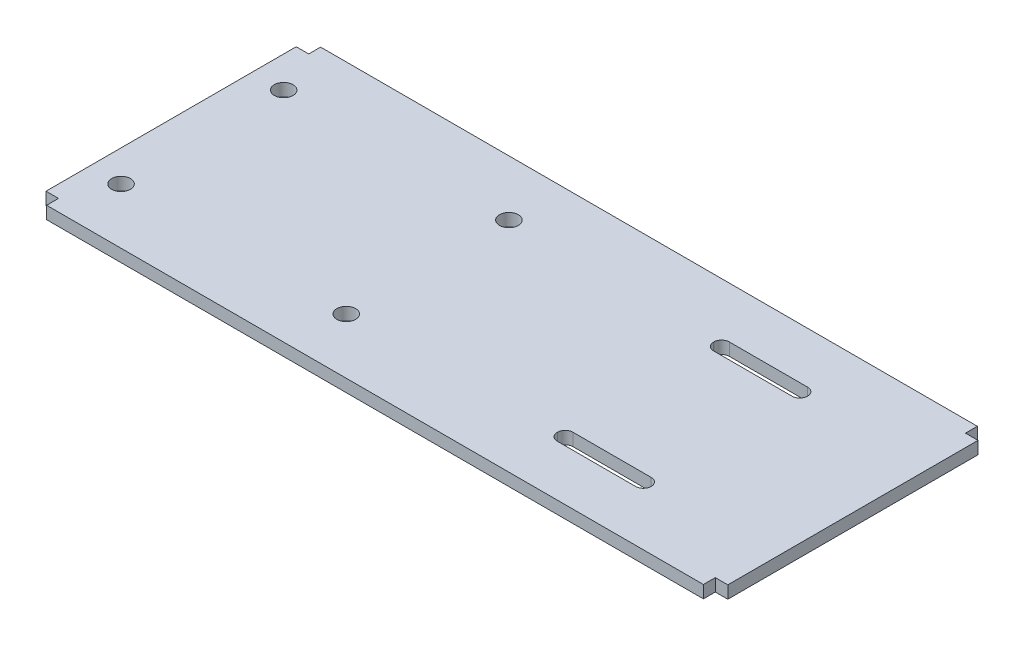
from build123d import *

# Parameters (mm, degrees)
BOSS_EXTRUDE1_DEPTH = 2.54
CUT_EXTRUDE1_DEPTH  = 3.54
CUT_EXTRUDE2_DEPTH  = 3.54


with BuildPart() as part:
    # Sketch1 → Boss-Extrude1 (new body)
    with BuildSketch(Plane(origin=(0, 0, 0), x_dir=(1, 0, 0), z_dir=(0, 1, 0))):
        Polygon((-66.675, 25.4), (-69.215, 25.4), (-69.215, -25.4), (-66.675, -25.4), (-66.675, -27.813), (66.675, -27.813), (66.675, -25.4), (69.215, -25.4), (69.215, 25.4), (66.675, 25.4), (66.675, 27.813), (-66.675, 27.813), align=None)
    extrude(amount=BOSS_EXTRUDE1_DEPTH)

    # Sketch2 → Cut-Extrude1 (cut, through all)
    with BuildSketch(Plane(origin=(0, 2.54, 0), x_dir=(1, 0, 0), z_dir=(0, 1, 0))):
        with BuildLine():
            ThreePointArc((-60.96, 16.51), (-64.212038418, 17.857038418), (-62.865, 14.605))
            Line((-62.865, 14.605), (-62.865, 16.51))
            Line((-62.865, 16.51), (-60.96, 16.51))
        make_face()
        with BuildLine():
            Line((-62.865, 16.51), (-62.865, 14.605))
            ThreePointArc((-62.865, 14.605), (-61.517961582, 15.162961582), (-60.96, 16.51))
            Line((-60.96, 16.51), (-62.865, 16.51))
        make_face()
        with BuildLine():
            ThreePointArc((-19.05, 16.51), (-18.492038418, 15.162961582), (-17.145, 14.605))
            Line((-17.145, 14.605), (-17.145, 16.51))
            Line((-17.145, 16.51), (-19.05, 16.51))
        make_face()
        with BuildLine():
            Line((-17.145, 16.51), (-17.145, 14.605))
            ThreePointArc((-17.145, 14.605), (-15.797961582, 15.162961582), (-15.24, 16.51))
            ThreePointArc((-15.24, 16.51), (-17.145, 18.415), (-19.05, 16.51))
            Line((-19.05, 16.51), (-17.145, 16.51))
        make_face()
        with BuildLine():
            ThreePointArc((-17.145, -14.605), (-18.492038418, -15.162961582), (-19.05, -16.51))
            Line((-19.05, -16.51), (-17.145, -16.51))
            Line((-17.145, -16.51), (-17.145, -14.605))
        make_face()
        with BuildLine():
            Line((-17.145, -16.51), (-19.05, -16.51))
            ThreePointArc((-19.05, -16.51), (-17.145, -18.415), (-15.24, -16.51))
            ThreePointArc((-15.24, -16.51), (-15.797961582, -15.162961582), (-17.145, -14.605))
            Line((-17.145, -14.605), (-17.145, -16.51))
        make_face()
        with BuildLine():
            Line((-62.865, -14.605), (-62.865, -16.51))
            Line((-62.865, -16.51), (-60.96, -16.51))
            ThreePointArc((-60.96, -16.51), (-61.517961582, -15.162961582), (-62.865, -14.605))
        make_face()
        with BuildLine():
            Line((-60.96, -16.51), (-62.865, -16.51))
            Line((-62.865, -16.51), (-62.865, -14.605))
            ThreePointArc((-62.865, -14.605), (-64.212038418, -17.857038418), (-60.96, -16.51))
        make_face()
    extrude(amount=-CUT_EXTRUDE1_DEPTH, mode=Mode.SUBTRACT)

    # Sketch3 → Cut-Extrude2 (cut, through all)
    with BuildSketch(Plane(origin=(0, 2.54, 0), x_dir=(1, 0, 0), z_dir=(0, 1, 0))):
        with BuildLine():
            Line((44.1325, 15.8877), (44.1325, 15.8623))
            ThreePointArc((44.1325, 15.8623), (43.671251759, 14.748748241), (42.5577, 14.2875))
            Line((42.5577, 14.2875), (26.6573, 14.2875))
            ThreePointArc((26.6573, 14.2875), (25.543748241, 14.748748241), (25.0825, 15.8623))
            Line((25.0825, 15.8623), (25.0825, 15.8877))
            ThreePointArc((25.0825, 15.8877), (25.543748241, 17.001251759), (26.6573, 17.4625))
            Line((26.6573, 17.4625), (42.5577, 17.4625))
            ThreePointArc((42.5577, 17.4625), (43.671251759, 17.001251759), (44.1325, 15.8877))
        make_face()
        with BuildLine():
            Line((42.5577, -17.4625), (26.6573, -17.4625))
            ThreePointArc((26.6573, -17.4625), (25.543748241, -17.001251759), (25.0825, -15.8877))
            Line((25.0825, -15.8877), (25.0825, -15.8623))
            ThreePointArc((25.0825, -15.8623), (25.543748241, -14.748748241), (26.6573, -14.2875))
            Line((26.6573, -14.2875), (42.5577, -14.2875))
            ThreePointArc((42.5577, -14.2875), (43.671251759, -14.748748241), (44.1325, -15.8623))
            Line((44.1325, -15.8623), (44.1325, -15.8877))
            ThreePointArc((44.1325, -15.8877), (43.671251759, -17.001251759), (42.5577, -17.4625))
        make_face()
    extrude(amount=-CUT_EXTRUDE2_DEPTH, mode=Mode.SUBTRACT)


solid = part.part
